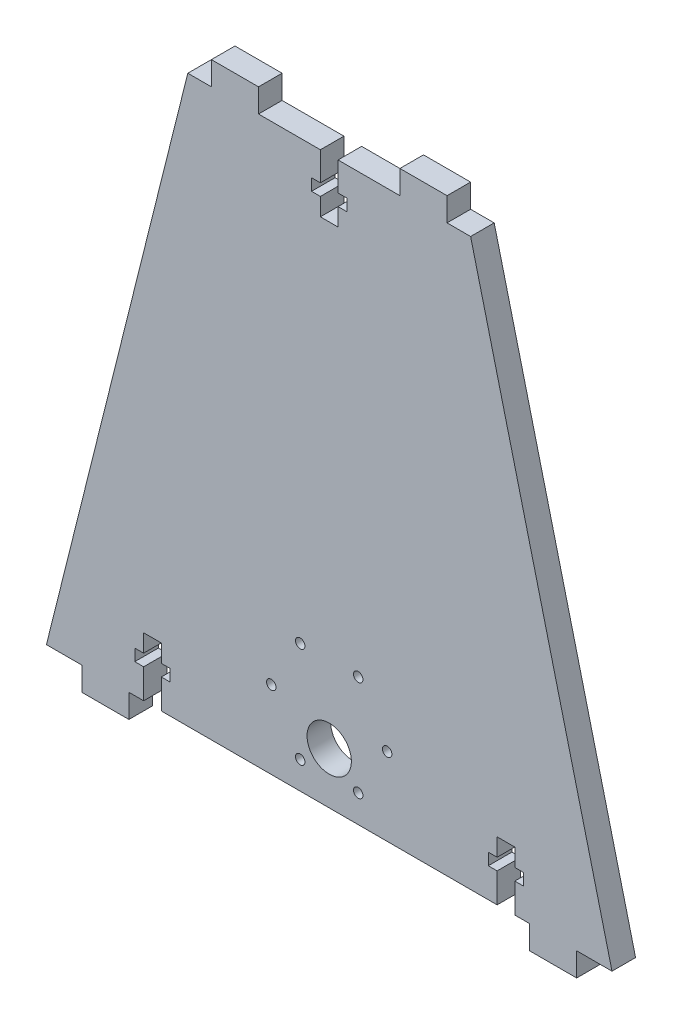
from build123d import *

# Parameters (mm, degrees)
BOSS_EXTRUDE1_DEPTH = 6.35
SKETCH4_R           = 5.969
SKETCH4_R_2         = 1.27
CUT_EXTRUDE3_DEPTH  = 6.35


with BuildPart() as part:
    # Sketch2 → Boss-Extrude1 (new body)
    with BuildSketch(Plane.XY):
        Polygon((0, 0), (-9.525, 0), (-9.525, -6.35), (-22.225, -6.35), (-22.225, 0), (-26.19375, 0), (-26.19375, 7.9375), (-23.8125, 7.9375), (-23.8125, 11.1125), (-26.19375, 11.1125), (-26.19375, 15.875), (-30.95625, 15.875), (-30.95625, 11.1125), (-33.3375, 11.1125), (-33.3375, 7.9375), (-30.95625, 7.9375), (-30.95625, 0), (-121.44375, 0), (-121.44375, 7.9375), (-119.0625, 7.9375), (-119.0625, 11.1125), (-121.44375, 11.1125), (-121.44375, 15.875), (-126.20625, 15.875), (-126.20625, 11.1125), (-128.5875, 11.1125), (-128.5875, 7.9375), (-126.20625, 7.9375), (-126.20625, 0), (-130.175, 0), (-130.175, -6.35), (-142.875, -6.35), (-142.875, 0), (-152.4, 0), (-114.3, 152.4), (-107.95, 152.4), (-107.95, 158.75), (-95.25, 158.75), (-95.25, 152.4), (-78.58125, 152.4), (-78.58125, 144.685169992), (-80.9625, 144.685169992), (-80.9625, 141.510169992), (-78.58125, 141.510169992), (-78.58125, 136.747669992), (-73.81875, 136.747669992), (-73.81875, 141.510169992), (-71.4375, 141.510169992), (-71.4375, 144.685169992), (-73.81875, 144.685169992), (-73.81875, 152.4), (-57.15, 152.4), (-57.15, 158.75), (-44.45, 158.75), (-44.45, 152.4), (-38.1, 152.4), align=None)
    extrude(amount=BOSS_EXTRUDE1_DEPTH)

    # Sketch4 → Cut-Extrude3 (cut)
    with BuildSketch(Plane(origin=(0, 0, 0), x_dir=(-1, 0, 0), z_dir=(0, 0, -1))):
        with Locations((76.2, 13.843)):
            Circle(SKETCH4_R)
        with Locations((68.3895, 34.483182833)):
            Circle(SKETCH4_R_2)
        with Locations((84.0105, 34.483182833)):
            Circle(SKETCH4_R_2)
        with Locations((91.821, 20.955)):
            Circle(SKETCH4_R_2)
        with Locations((84.0105, 7.426817167)):
            Circle(SKETCH4_R_2)
        with Locations((68.3895, 7.426817167)):
            Circle(SKETCH4_R_2)
        with Locations((60.579, 20.955)):
            Circle(SKETCH4_R_2)
    extrude(amount=-CUT_EXTRUDE3_DEPTH, mode=Mode.SUBTRACT)


solid = part.part
